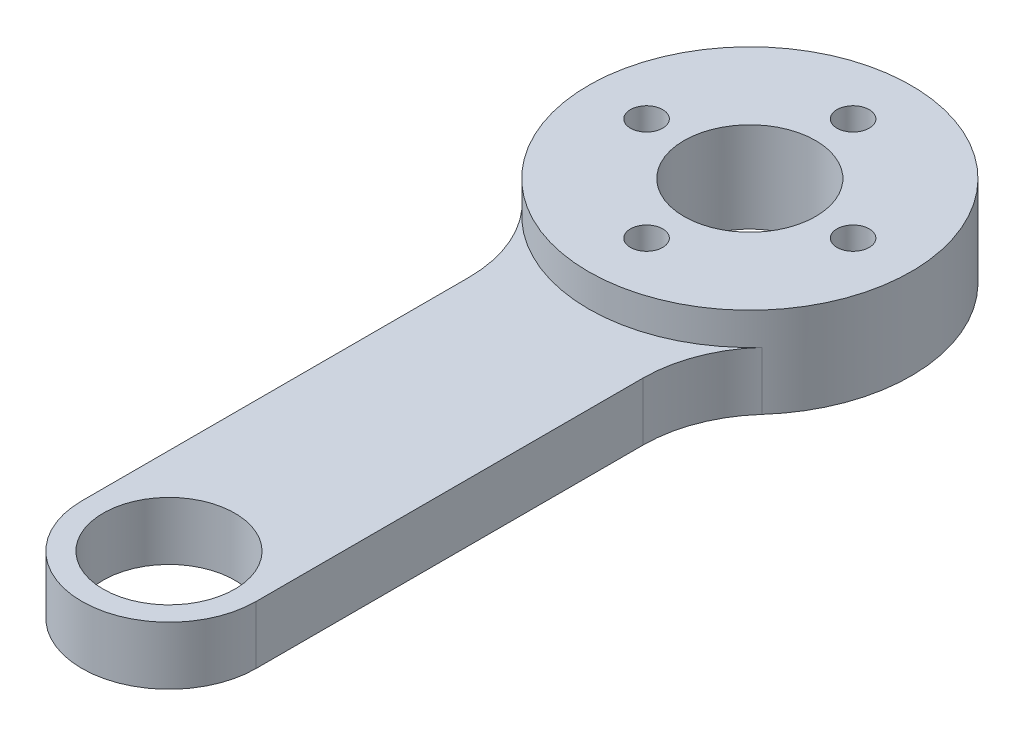
from build123d import *

# Parameters (mm, degrees)
SKETCH2_R           = 1.25
SKETCH2_R_2         = 5.1
BOSS_EXTRUDE2_DEPTH = 4.5
FILLET1_R           = 10
SKETCH4_R           = 2
CUT_EXTRUDE1_DEPTH  = 2
SKETCH5_R           = 12.5
SKETCH5_R_2         = 1.25
BOSS_EXTRUDE3_DEPTH = 2.5
SKETCH8_R           = 5.1
CUT_EXTRUDE5_DEPTH  = 10


with BuildPart() as part:
    # Sketch2 → Boss-Extrude2 (new body)
    with BuildSketch(Plane(origin=(0, 0, 0), x_dir=(1, 0, 0), z_dir=(0, 1, 0))):
        with BuildLine():
            Line((6.75, -45), (6.75, -10.520812706))
            ThreePointArc((6.75, -10.520812706), (0, 12.5), (-6.75, -10.520812706))
            Line((-6.75, -10.520812706), (-6.75, -45))
            ThreePointArc((-6.75, -45), (0, -51.75), (6.75, -45))
        make_face()
        with Locations((8, 0)):
            Circle(SKETCH2_R, mode=Mode.SUBTRACT)
        with Locations((0, -8)):
            Circle(SKETCH2_R, mode=Mode.SUBTRACT)
        with Locations((-8, 0)):
            Circle(SKETCH2_R, mode=Mode.SUBTRACT)
        with Locations((0, 8)):
            Circle(SKETCH2_R, mode=Mode.SUBTRACT)
        with Locations((0, -45)):
            Circle(SKETCH2_R_2, mode=Mode.SUBTRACT)
    extrude(amount=BOSS_EXTRUDE2_DEPTH)

    # Fillet1
    fillet1_edges = [part.edges().sort_by_distance(p)[0] for p in [
        (-6.75, 2.25, 10.520812706),
        (6.75, 2.25, 10.520812706),
    ]]
    fillet(fillet1_edges, radius=FILLET1_R)

    # Sketch4 → Cut-Extrude1 (cut)
    with BuildSketch(Plane.XZ):
        with Locations((0, 8)):
            Circle(SKETCH4_R)
        with Locations((-8, 0)):
            Circle(SKETCH4_R)
        with Locations((8, 0)):
            Circle(SKETCH4_R)
        with Locations((0, -8)):
            Circle(SKETCH4_R)
    extrude(amount=-CUT_EXTRUDE1_DEPTH, mode=Mode.SUBTRACT)

    # Sketch5 → Boss-Extrude3 (add)
    with BuildSketch(Plane(origin=(0, 4.5, 0), x_dir=(1, 0, 0), z_dir=(0, 1, 0))):
        Circle(SKETCH5_R)
        with Locations((8, 0)):
            Circle(SKETCH5_R_2, mode=Mode.SUBTRACT)
        with Locations((0, 8)):
            Circle(SKETCH5_R_2, mode=Mode.SUBTRACT)
        with Locations((-8, 0)):
            Circle(SKETCH5_R_2, mode=Mode.SUBTRACT)
        with Locations((0, -8)):
            Circle(SKETCH5_R_2, mode=Mode.SUBTRACT)
    extrude(amount=BOSS_EXTRUDE3_DEPTH)

    # Sketch8 → Cut-Extrude5 (cut)
    with BuildSketch(Plane.XZ):
        Circle(SKETCH8_R)
    extrude(amount=-CUT_EXTRUDE5_DEPTH, mode=Mode.SUBTRACT)


solid = part.part
